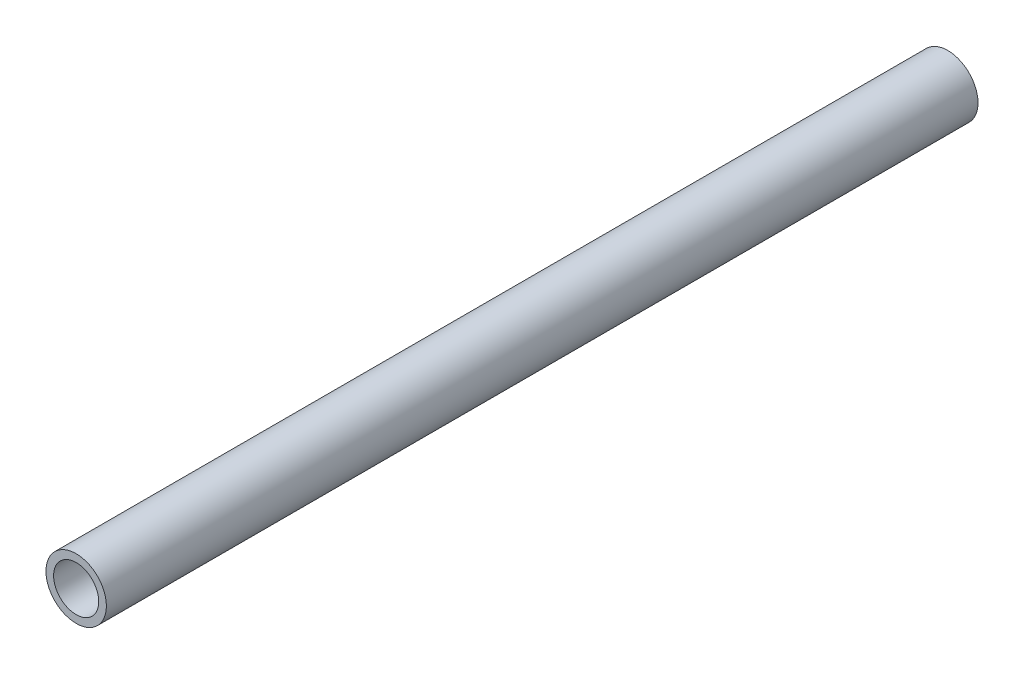
from build123d import *

# Parameters (mm, degrees)
SKETCH1_R           = 2.125
SKETCH1_R_2         = 1.5875
BOSS_EXTRUDE1_DEPTH = 61.3


with BuildPart() as part:
    # Sketch1 → Boss-Extrude1 (new body)
    with BuildSketch(Plane.XY):
        Circle(SKETCH1_R)
        Circle(SKETCH1_R_2, mode=Mode.SUBTRACT)
    extrude(amount=BOSS_EXTRUDE1_DEPTH)


solid = part.part
